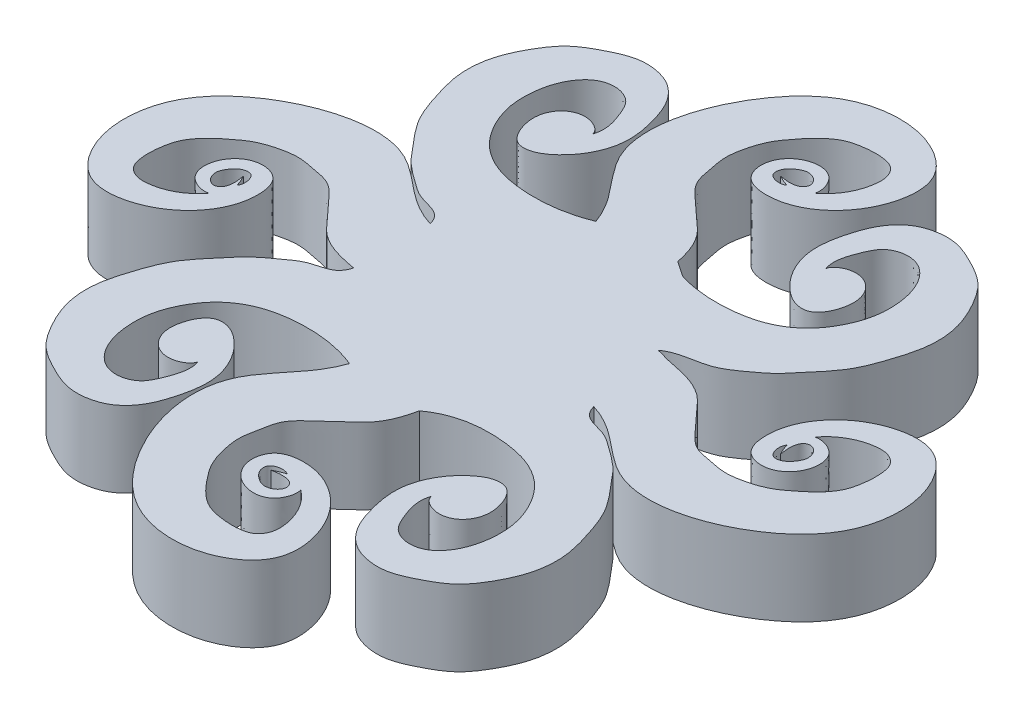
from build123d import *

# Parameters (mm, degrees)
BOSS_EXTRUDE2_DEPTH = 10
SKETCH2_R           = 13.166490973
BOSS_EXTRUDE4_DEPTH = 10


with BuildPart() as part:
    # Sketch1 → Boss-Extrude2 (new body)
    with BuildSketch(Plane(origin=(0, 0, 0), x_dir=(1, 0, 0), z_dir=(0, 1, 0))):
        with BuildLine():
            add(Edge.make_bspline(
                [(34.188363514, 44.956596514), (33.701598666, 43.048036253), (30.95739019, 43.115245722), (28.118998449, 40.970403917), (25.878188681, 39.331460779), (24.404677264, 37.426125449), (22.941084472, 35.794270593), (21.235407173, 33.479842018), (19.985078829, 30.008395243), (18.889058016, 26.247854831), (19.108830289, 22.745657785), (19.725757566, 20.92378151), (20.092106533, 20.092106533)],
                knots=[0, 0, 0, 0, 0.047266575, 0.084492057, 0.118112524, 0.141184856, 0.165634032, 0.192608699, 0.237940364, 0.289819658, 0.32418302, 0.354847276, 0.354847276, 0.354847276, 0.354847276], degree=3))
            Line((20.092106533, 20.092106533), (26.01328336, 26.01328336))
            add(Edge.make_bspline(
                [(26.01328336, 26.01328336), (26.052529787, 26.268426348), (26.278747771, 27.439968658), (27.14866517, 29.654095335), (29.108744684, 32.428855421), (31.966179785, 34.173665176), (33.996161891, 34.692283129), (34.836749566, 34.836749566)],
                knots=[0.460515809, 0.460515809, 0.460515809, 0.460515809, 0.478276136, 0.542635526, 0.623024021, 0.708168641, 0.766773984, 0.766773984, 0.766773984, 0.766773984], degree=3))
            Line((34.836749566, 34.836749566), (42.014455927, 42.014455927))
            add(Edge.make_bspline(
                [(34.188363514, 44.956596514), (34.412632763, 44.909046824), (35.135898032, 44.740206472), (36.778212553, 44.111022962), (39.947733796, 44.722787853), (41.031599473, 42.901571115), (42.014455927, 42.014455927)],
                knots=[0.810573593, 0.810573593, 0.810573593, 0.810573593, 0.822647339, 0.849801987, 0.902946428, 0.968114768, 0.968114768, 0.968114768, 0.968114768], degree=3))
        make_face()
        with BuildLine():
            Line((26.01328336, 26.01328336), (20.092106533, 20.092106533))
            add(Edge.make_bspline(
                [(20.092106533, 20.092106533), (20.391405304, 19.412646998), (21.173087456, 17.934573709), (22.855976348, 15.446940047), (25.899000157, 13.736428609), (29.019853456, 12.320498914), (31.692855633, 12.529433804), (34.075188007, 13.361697368), (36.025463952, 15.374095844), (37.304367596, 18.905964925), (38.234125799, 23.697087846), (36.050935714, 27.683689746), (33.885547102, 29.409321454), (32.695248955, 30.106562845), (30.959854801, 30.362175237), (29.737427553, 29.109049648), (29.167704554, 27.794524876), (28.848219551, 26.33981112), (29.051776005, 24.637379388), (29.977289897, 23.259457338), (31.684162076, 22.403328871), (33.422522957, 22.601417527), (34.534014203, 23.529934128), (34.637188493, 23.988642652), (34.646815974, 24.066379751)],
                knots=[0.354847276, 0.354847276, 0.354847276, 0.354847276, 0.379899275, 0.41085446, 0.455212464, 0.495953054, 0.524736546, 0.543496723, 0.580828475, 0.614309776, 0.670605327, 0.741152887, 0.752796809, 0.764260994, 0.788347673, 0.804360394, 0.819458631, 0.836969807, 0.854153952, 0.876412827, 0.889806592, 0.917326832, 0.931104592, 0.933826593, 0.933826593, 0.933826593, 0.933826593], degree=3))
            add(Edge.make_bspline(
                [(34.646815974, 24.066379751), (35.14201703, 22.640852122), (34.457931313, 20.557953149), (33.229845661, 17.848412965), (31.041923292, 16.974982467), (28.723356671, 17.471160138), (26.799485597, 19.52788522), (25.866296411, 22.561566295), (25.844067539, 24.913202835), (26.01328336, 26.01328336)],
                knots=[0, 0, 0, 0, 0.099619212, 0.145832416, 0.199041029, 0.246529323, 0.301572291, 0.383939961, 0.460515809, 0.460515809, 0.460515809, 0.460515809], degree=3))
        make_face()
        with BuildLine():
            add(Edge.make_bspline(
                [(79.907893467, 20.092106533), (79.608594696, 19.412646998), (78.826912544, 17.934573709), (77.144023652, 15.446940047), (74.100999843, 13.736428609), (70.980146544, 12.320498914), (68.307144367, 12.529433804), (65.924811993, 13.361697368), (63.974536048, 15.374095844), (62.695632404, 18.905964925), (61.765874201, 23.697087846), (63.949064286, 27.683689746), (66.114452898, 29.409321454), (67.304751045, 30.106562845), (69.040145199, 30.362175237), (70.262572447, 29.109049648), (70.832295446, 27.794524876), (71.151780449, 26.33981112), (70.948223995, 24.637379388), (70.022710103, 23.259457338), (68.315837924, 22.403328871), (66.577477043, 22.601417527), (65.465985797, 23.529934128), (65.362811507, 23.988642652), (65.353184026, 24.066379751)],
                knots=[0.354847276, 0.354847276, 0.354847276, 0.354847276, 0.379899275, 0.41085446, 0.455212464, 0.495953054, 0.524736546, 0.543496723, 0.580828475, 0.614309776, 0.670605327, 0.741152887, 0.752796809, 0.764260994, 0.788347673, 0.804360394, 0.819458631, 0.836969807, 0.854153952, 0.876412827, 0.889806592, 0.917326832, 0.931104592, 0.933826593, 0.933826593, 0.933826593, 0.933826593], degree=3))
            Line((79.907893467, 20.092106533), (73.986720472, 26.013279528))
            add(Edge.make_bspline(
                [(65.353184026, 24.066379751), (64.857982968, 22.640852128), (65.542068695, 20.557953125), (66.770154327, 17.848413003), (68.958076762, 16.974982309), (71.276643142, 17.471160691), (73.200515405, 19.527882257), (74.133699339, 22.561587505), (74.155943652, 24.91317945), (73.986720472, 26.013279528)],
                knots=[0, 0, 0, 0, 0.098273737, 0.143862778, 0.196352745, 0.243199654, 0.297499202, 0.3787544, 0.454296315, 0.454296315, 0.454296315, 0.454296315], degree=3))
        make_face()
        with BuildLine():
            Line((73.986720472, 26.013279528), (79.907893467, 20.092106533))
            add(Edge.make_bspline(
                [(65.811636486, 44.956596514), (66.298401334, 43.048036253), (69.04260981, 43.115245722), (71.881001551, 40.970403917), (74.121811319, 39.331460779), (75.595322736, 37.426125449), (77.058915528, 35.794270593), (78.764592827, 33.479842018), (80.014921171, 30.008395243), (81.110941984, 26.247854831), (80.891169711, 22.745657785), (80.274242434, 20.92378151), (79.907893467, 20.092106533)],
                knots=[0, 0, 0, 0, 0.047266575, 0.084492057, 0.118112524, 0.141184856, 0.165634032, 0.192608699, 0.237940364, 0.289819658, 0.32418302, 0.354847276, 0.354847276, 0.354847276, 0.354847276], degree=3))
            add(Edge.make_bspline(
                [(58.999511619, 43.561039694), (61.189200326, 45.409124558), (63.564168332, 45.615347007), (65.811636486, 44.956596514)],
                knots=[0.018252545, 0.018252545, 0.018252545, 0.018252545, 0.091662786, 0.091662786, 0.091662786, 0.091662786], degree=3))
            add(Edge.make_bspline(
                [(57.985544073, 42.014455927), (58.366591704, 42.436627849), (58.726230487, 42.929989082), (58.999511619, 43.561039694)],
                knots=[0.968114768, 0.968114768, 0.968114768, 0.968114768, 0.996106896, 0.996106896, 0.996106896, 0.996106896], degree=3))
            Line((57.985544073, 42.014455927), (65.166884419, 34.833115581))
            add(Edge.make_bspline(
                [(73.986720472, 26.013279528), (73.947473207, 26.268421402), (73.721246456, 27.439985024), (72.851273596, 29.654276415), (70.891559836, 32.427954896), (68.033533359, 34.176288831), (66.007033807, 34.687361047), (65.166884419, 34.833115581)],
                knots=[0.454296315, 0.454296315, 0.454296315, 0.454296315, 0.471816454, 0.535306594, 0.614609348, 0.698603989, 0.756359253, 0.756359253, 0.756359253, 0.756359253], degree=3))
        make_face()
        with BuildLine():
            add(Edge.make_bspline(
                [(20.092106533, 79.907893467), (20.391405304, 80.587353002), (21.173087456, 82.065426291), (22.855976348, 84.553059953), (25.899000157, 86.263571391), (29.019853456, 87.679501086), (31.692855633, 87.470566196), (34.075188007, 86.638302632), (36.025463952, 84.625904156), (37.304367596, 81.094035075), (38.234125799, 76.302912154), (36.050935714, 72.316310254), (33.885547102, 70.590678546), (32.695248955, 69.893437155), (30.959854801, 69.637824763), (29.737427553, 70.890950352), (29.167704554, 72.205475124), (28.848219551, 73.66018888), (29.051776005, 75.362620612), (29.977289897, 76.740542662), (31.684162076, 77.596671129), (33.422522957, 77.398582473), (34.534014203, 76.470065872), (34.637188493, 76.011357348), (34.646815974, 75.933620249)],
                knots=[0.354847276, 0.354847276, 0.354847276, 0.354847276, 0.379899275, 0.41085446, 0.455212464, 0.495953054, 0.524736546, 0.543496723, 0.580828475, 0.614309776, 0.670605327, 0.741152887, 0.752796809, 0.764260994, 0.788347673, 0.804360394, 0.819458631, 0.836969807, 0.854153952, 0.876412827, 0.889806592, 0.917326832, 0.931104592, 0.933826593, 0.933826593, 0.933826593, 0.933826593], degree=3))
            Line((20.092106533, 79.907893467), (26.01328336, 73.98671664))
            add(Edge.make_bspline(
                [(34.646815974, 75.933620249), (35.14201703, 77.359147878), (34.457931313, 79.442046851), (33.229845661, 82.151587035), (31.041923292, 83.025017533), (28.723356671, 82.528839862), (26.799485597, 80.47211478), (25.866296411, 77.438433705), (25.844067539, 75.086797165), (26.01328336, 73.98671664)],
                knots=[0, 0, 0, 0, 0.099619212, 0.145832416, 0.199041029, 0.246529323, 0.301572291, 0.383939961, 0.460515809, 0.460515809, 0.460515809, 0.460515809], degree=3))
        make_face()
        with BuildLine():
            Line((26.01328336, 73.98671664), (20.092106533, 79.907893467))
            add(Edge.make_bspline(
                [(34.188363514, 55.043403486), (33.701598666, 56.951963747), (30.95739019, 56.884754278), (28.118998449, 59.029596083), (25.878188681, 60.668539221), (24.404677264, 62.573874551), (22.941084472, 64.205729407), (21.235407173, 66.520157982), (19.985078829, 69.991604757), (18.889058016, 73.752145169), (19.108830289, 77.254342215), (19.725757566, 79.07621849), (20.092106533, 79.907893467)],
                knots=[0, 0, 0, 0, 0.047266575, 0.084492057, 0.118112524, 0.141184856, 0.165634032, 0.192608699, 0.237940364, 0.289819658, 0.32418302, 0.354847276, 0.354847276, 0.354847276, 0.354847276], degree=3))
            add(Edge.make_bspline(
                [(41.228865774, 56.63831337), (38.976587284, 54.606309361), (36.514201974, 54.361682043), (34.188363514, 55.043403486)],
                knots=[0.015692694, 0.015692694, 0.015692694, 0.015692694, 0.091662786, 0.091662786, 0.091662786, 0.091662786], degree=3))
            ThreePointArc((41.228865774, 56.63831337), (41.538778856, 57.029063717), (41.866085127, 57.405364869))
            ThreePointArc((41.866085127, 57.405364869), (42.041771895, 57.593853135), (42.221825407, 57.778174593))
            Line((42.221825407, 57.778174593), (34.836749566, 65.163250434))
            add(Edge.make_bspline(
                [(26.01328336, 73.98671664), (26.052529787, 73.731573652), (26.278747771, 72.560031342), (27.14866517, 70.345904665), (29.108744684, 67.571144579), (31.966179785, 65.826334824), (33.996161891, 65.307716871), (34.836749566, 65.163250434)],
                knots=[0.460515809, 0.460515809, 0.460515809, 0.460515809, 0.478276136, 0.542635526, 0.623024021, 0.708168641, 0.766773984, 0.766773984, 0.766773984, 0.766773984], degree=3))
        make_face()
        with BuildLine():
            add(Edge.make_bspline(
                [(16.160494625, 43.96111936), (14.986864586, 42.379235873), (12.592744084, 41.012743048), (9.465709528, 40.96551986), (8.026422717, 41.910411497), (7.550806508, 43.748330363), (7.647195031, 45.75277335), (8.069282603, 47.971716016), (9.432801166, 49.882198225), (11.219922046, 51.401479152), (13.316786407, 52.95305245), (15.672674157, 53.673961961), (18.087107893, 54.068440293), (20.330842421, 53.550169721), (22.892165795, 53.186443439), (24.769702556, 51.12420354), (26.684889568, 49.06748532), (28.919014682, 46.346067881), (31.874813568, 45.376238518), (33.79367813, 45.040277927), (34.188363514, 44.956596514)],
                knots=[0, 0, 0, 0, 0.103133744, 0.133672356, 0.160054586, 0.186139677, 0.228666647, 0.265873413, 0.302525941, 0.34902888, 0.389122541, 0.4381572, 0.476950983, 0.515572502, 0.558652472, 0.608310362, 0.655131306, 0.708599715, 0.789325333, 0.810573593, 0.810573593, 0.810573593, 0.810573593], degree=3))
            add(Edge.make_bspline(
                [(34.188363514, 44.956596514), (34.412632763, 44.909046824), (35.135898032, 44.740206472), (36.778212553, 44.111022962), (39.947733796, 44.722787853), (41.031599473, 42.901571115), (42.014455927, 42.014455927)],
                knots=[0.810573593, 0.810573593, 0.810573593, 0.810573593, 0.822647339, 0.849801987, 0.902946428, 0.968114768, 0.968114768, 0.968114768, 0.968114768], degree=3))
            Line((42.014455927, 42.014455927), (42.221825407, 42.221825407))
            ThreePointArc((42.221825407, 42.221825407), (42.041771895, 42.406146865), (41.866085127, 42.594635131))
            ThreePointArc((41.866085127, 42.594635131), (39.011305998, 49.501397827), (41.228865774, 56.63831337))
            add(Edge.make_bspline(
                [(41.228865774, 56.63831337), (38.976587284, 54.606309361), (36.514201974, 54.361682043), (34.188363514, 55.043403486)],
                knots=[0.015692694, 0.015692694, 0.015692694, 0.015692694, 0.091662786, 0.091662786, 0.091662786, 0.091662786], degree=3))
            add(Edge.make_bspline(
                [(34.188363514, 55.043403486), (32.988757012, 55.395017534), (29.597040142, 57.138700626), (22.985132601, 64.13491873), (10.103143612, 60.465996346), (1.846885834, 51.957990237), (1.634403442, 42.951143194), (6.767093741, 36.729262075), (13.487499365, 37.728070412), (18.147246483, 41.515948147), (19.922544307, 46.038195425), (19.184657897, 50.305501367), (15.417936423, 51.104416641), (12.630967645, 48.726147208), (12.560989705, 44.684698735), (15.201485328, 43.712661691), (16.160494625, 43.96111936)],
                knots=[0.091662786, 0.091662786, 0.091662786, 0.091662786, 0.130846168, 0.205907606, 0.373668348, 0.458524244, 0.563429024, 0.616001906, 0.684326796, 0.743988773, 0.794856123, 0.830050979, 0.857943881, 0.895209986, 0.928487465, 0.961873919, 0.961873919, 0.961873919, 0.961873919], degree=3))
        make_face()
        with BuildLine():
            add(Edge.make_bspline(
                [(16.480040826, 48.178626232), (16.592128106, 47.528012831), (16.737195952, 46.59846685), (16.301672382, 45.417068995), (15.580197675, 45.116345164), (14.941408745, 45.337928813), (14.493316803, 45.783133929), (14.277188548, 46.356103882), (14.1963921, 46.948802008), (14.438639408, 47.616279928), (14.910750096, 48.31149619), (15.627269466, 48.946980069), (17.316467934, 49.150329476), (17.504986229, 47.195958075), (17.092499363, 46.720147552)],
                knots=[0, 0, 0, 0, 0.16636553, 0.241726144, 0.29922749, 0.344909014, 0.407108122, 0.454045417, 0.499648781, 0.556760972, 0.630203201, 0.713356713, 0.798617516, 1, 1, 1, 1], degree=3))
            add(Edge.make_bspline(
                [(17.092499363, 46.720147552), (16.962306122, 47.149811619), (16.76240491, 47.634622725), (16.480040826, 48.178626232)],
                knots=[0.992293125, 0.992293125, 0.992293125, 0.992293125, 1, 1, 1, 1], degree=3))
        make_face(mode=Mode.SUBTRACT)
        with BuildLine():
            add(Edge.make_bspline(
                [(63.619252851, 55.615166428), (65.217749299, 56.807977108), (68.566089002, 56.61671767), (71.887711223, 59.017839913), (74.120685104, 60.670512487), (75.595591616, 62.57340344), (77.058834536, 64.205871316), (78.764632843, 66.520087869), (80.014906002, 69.991631335), (81.110944653, 73.752140493), (80.891169349, 77.25434267), (80.27424218, 79.076218783), (79.907893422, 79.907893422)],
                knots=[0, 0, 0, 0, 0.064389944, 0.100946377, 0.133962587, 0.156620243, 0.180629997, 0.207119851, 0.251636775, 0.302583648, 0.336329402, 0.366442526, 0.366442526, 0.366442526, 0.366442526], degree=3))
            Line((79.907893422, 79.907893422), (73.986716963, 73.986716963))
            add(Edge.make_bspline(
                [(73.986716963, 73.986716963), (73.947470464, 73.731574111), (73.721251671, 72.56002965), (72.85132918, 70.34588619), (70.891283414, 67.571236458), (68.033804779, 65.826069284), (66.004157648, 65.308221706), (65.163622957, 65.163622957)],
                knots=[0.479848557, 0.479848557, 0.479848557, 0.479848557, 0.498354438, 0.565415671, 0.649178921, 0.737897959, 0.798956978, 0.798956978, 0.798956978, 0.798956978], degree=3))
            Line((65.163622957, 65.163622957), (57.985544073, 57.985544073))
            add(Edge.make_bspline(
                [(63.619252851, 55.615166428), (62.609079309, 55.770749147), (60.04783606, 55.284656108), (58.968400527, 57.098428885), (57.985544073, 57.985544073)],
                knots=[0.850285574, 0.850285574, 0.850285574, 0.850285574, 0.902946428, 0.968114768, 0.968114768, 0.968114768, 0.968114768], degree=3))
        make_face()
        with BuildLine():
            Line((73.986716963, 73.986716963), (79.907893422, 79.907893422))
            add(Edge.make_bspline(
                [(79.907893422, 79.907893422), (79.608594677, 80.587353011), (78.826912774, 82.065425919), (77.144023601, 84.553060043), (74.100999858, 86.263571365), (70.980146542, 87.67950109), (68.307144368, 87.470566196), (65.924811993, 86.638302632), (63.974536048, 84.625904156), (62.695632404, 81.094035075), (61.765874201, 76.302912154), (63.949064286, 72.316310254), (66.114452898, 70.590678546), (67.304751045, 69.893437155), (69.040145199, 69.637824763), (70.262572447, 70.890950352), (70.832295446, 72.205475124), (71.151780449, 73.66018888), (70.948223995, 75.362620612), (70.022710103, 76.740542662), (68.315837924, 77.596671129), (66.577477043, 77.398582473), (65.465985797, 76.470065872), (65.362811507, 76.011357348), (65.353184026, 75.933620249)],
                knots=[0.366442526, 0.366442526, 0.366442526, 0.366442526, 0.391044274, 0.421443106, 0.465003868, 0.505012233, 0.533278402, 0.551701404, 0.588362197, 0.621241742, 0.6765255, 0.745805117, 0.757239764, 0.768497904, 0.792151676, 0.807876602, 0.822703481, 0.83989993, 0.856775226, 0.878634045, 0.891787086, 0.918812708, 0.932342842, 0.93501592, 0.93501592, 0.93501592, 0.93501592], degree=3))
            add(Edge.make_bspline(
                [(65.353184026, 75.933620249), (64.857982969, 77.359147877), (65.542068688, 79.442046853), (66.770154338, 82.151587031), (68.958076713, 83.025017549), (71.276643312, 82.528839806), (73.200514495, 80.472115082), (74.133703218, 77.438431519), (74.155933495, 75.086799504), (73.986716963, 73.986716963)],
                knots=[0, 0, 0, 0, 0.103801283, 0.151954543, 0.207396883, 0.256878763, 0.314232465, 0.400057977, 0.479848557, 0.479848557, 0.479848557, 0.479848557], degree=3))
        make_face()
        with BuildLine():
            add(Edge.make_bspline(
                [(58.999511619, 43.561039694), (61.189200326, 45.409124558), (63.564168332, 45.615347007), (65.811636486, 44.956596514)],
                knots=[0.018252545, 0.018252545, 0.018252545, 0.018252545, 0.091662786, 0.091662786, 0.091662786, 0.091662786], degree=3))
            add(Edge.make_bspline(
                [(65.811636486, 44.956596514), (67.011242988, 44.604982466), (70.402959858, 42.861299374), (77.014867399, 35.86508127), (89.896856388, 39.534003654), (98.153114166, 48.042009763), (98.365596558, 57.048856806), (93.232906259, 63.270737925), (86.512500635, 62.271929588), (81.852753517, 58.484051853), (80.077455693, 53.961804575), (80.815342103, 49.694498633), (84.582063577, 48.895583359), (87.369032355, 51.273852792), (87.439010295, 55.315301265), (84.798514672, 56.287338309), (83.839505375, 56.03888064)],
                knots=[0.091662786, 0.091662786, 0.091662786, 0.091662786, 0.130846168, 0.205907606, 0.373668348, 0.458524244, 0.563429024, 0.616001906, 0.684326796, 0.743988773, 0.794856123, 0.830050979, 0.857943881, 0.895209986, 0.928487465, 0.961873919, 0.961873919, 0.961873919, 0.961873919], degree=3))
            add(Edge.make_bspline(
                [(83.839505375, 56.03888064), (85.013135414, 57.620764127), (87.407255916, 58.987256952), (90.534290472, 59.03448014), (91.973577283, 58.089588503), (92.449193492, 56.251669637), (92.352804969, 54.24722665), (91.930717397, 52.028283984), (90.567198834, 50.117801775), (88.780077954, 48.598520848), (86.683213593, 47.04694755), (84.327325843, 46.326038039), (81.912892107, 45.931559707), (79.669157579, 46.449830279), (77.107834205, 46.813556561), (75.230297444, 48.87579646), (73.315110432, 50.93251468), (71.080985318, 53.653932119), (67.895599183, 54.699091525), (65.241878897, 55.115064238), (64.166652748, 55.526991767), (63.647047863, 55.610785299)],
                knots=[0, 0, 0, 0, 0.103133744, 0.133672356, 0.160054586, 0.186139677, 0.228666647, 0.265873413, 0.302525941, 0.34902888, 0.389122541, 0.4381572, 0.476950983, 0.515572502, 0.558652472, 0.608310362, 0.655131306, 0.708599715, 0.789325333, 0.822647339, 0.849801987, 0.849801987, 0.849801987, 0.849801987], degree=3))
            add(Edge.make_bspline(
                [(63.647047863, 55.610785299), (63.637794424, 55.612277545), (63.628529309, 55.613737706), (63.619252851, 55.615166428)],
                knots=[0.849801987, 0.849801987, 0.849801987, 0.849801987, 0.850285574, 0.850285574, 0.850285574, 0.850285574], degree=3))
            add(Edge.make_bspline(
                [(63.619252851, 55.615166428), (62.609079309, 55.770749147), (60.04783606, 55.284656108), (58.968400527, 57.098428885), (57.985544073, 57.985544073)],
                knots=[0.850285574, 0.850285574, 0.850285574, 0.850285574, 0.902946428, 0.968114768, 0.968114768, 0.968114768, 0.968114768], degree=3))
            add(Edge.make_bspline(
                [(57.985544073, 57.985544073), (58.419587249, 57.5046571), (58.825852446, 56.931402004), (59.108348304, 56.167494723)],
                knots=[0.968114768, 0.968114768, 0.968114768, 0.968114768, 1, 1, 1, 1], degree=3))
            ThreePointArc((59.108348304, 56.167494723), (60.516459275, 53.225536285), (61, 50))
            ThreePointArc((61, 50), (60.516459275, 46.774463715), (59.108348304, 43.832505277))
            add(Edge.make_bspline(
                [(58.999511619, 43.561039694), (59.037519157, 43.648805286), (59.073856294, 43.739234181), (59.108348304, 43.832505277)],
                knots=[0.996106896, 0.996106896, 0.996106896, 0.996106896, 1, 1, 1, 1], degree=3))
        make_face()
        with BuildLine():
            add(Edge.make_bspline(
                [(83.519959174, 51.821373768), (83.407871894, 52.471987169), (83.262804048, 53.40153315), (83.698327618, 54.582931005), (84.419802325, 54.883654836), (85.058591255, 54.662071187), (85.506683197, 54.216866071), (85.722811452, 53.643896118), (85.8036079, 53.051197992), (85.561360592, 52.383720072), (85.089249904, 51.68850381), (84.372730534, 51.053019931), (82.683532066, 50.849670524), (82.495013771, 52.804041925), (82.907500637, 53.279852448)],
                knots=[0, 0, 0, 0, 0.16636553, 0.241726144, 0.29922749, 0.344909014, 0.407108122, 0.454045417, 0.499648781, 0.556760972, 0.630203201, 0.713356713, 0.798617516, 1, 1, 1, 1], degree=3))
            add(Edge.make_bspline(
                [(82.907500637, 53.279852448), (83.037693878, 52.850188381), (83.23759509, 52.365377275), (83.519959174, 51.821373768)],
                knots=[0.992293125, 0.992293125, 0.992293125, 0.992293125, 1, 1, 1, 1], degree=3))
        make_face(mode=Mode.SUBTRACT)
        with BuildLine():
            Line((42.014455927, 42.014455927), (34.836749566, 34.836749566))
            add(Edge.make_bspline(
                [(34.836749566, 34.836749566), (35.127532864, 34.886724635), (38.490614827, 35.369450815), (41.950755989, 34.971413705), (44.827882558, 33.782431504)],
                knots=[0.766773984, 0.766773984, 0.766773984, 0.766773984, 0.787047246, 1, 1, 1, 1], degree=3))
            add(Edge.make_bspline(
                [(43.561039694, 41.000488381), (45.520791717, 38.678491725), (45.634273864, 36.148148995), (44.827882558, 33.782431504)],
                knots=[0.018252545, 0.018252545, 0.018252545, 0.018252545, 0.096098466, 0.096098466, 0.096098466, 0.096098466], degree=3))
            add(Edge.make_bspline(
                [(42.014455927, 42.014455927), (42.436627849, 41.633408296), (42.929989082, 41.273769513), (43.561039694, 41.000488381)],
                knots=[0.968114768, 0.968114768, 0.968114768, 0.968114768, 0.996106896, 0.996106896, 0.996106896, 0.996106896], degree=3))
        make_face()
        with BuildLine():
            add(Edge.make_bspline(
                [(65.166884419, 34.833115581), (64.875106499, 34.883735096), (61.309745267, 35.407065501), (57.596457215, 35.058299276), (54.806676969, 32.993134393)],
                knots=[0.756359253, 0.756359253, 0.756359253, 0.756359253, 0.776417246, 1, 1, 1, 1], degree=3))
            Line((65.166884419, 34.833115581), (57.985544073, 42.014455927))
            add(Edge.make_bspline(
                [(54.806676969, 32.993134393), (54.936903945, 33.621537936), (55.115064238, 34.758121103), (55.888977038, 36.778212553), (55.277212147, 39.947733796), (57.098428885, 41.031599473), (57.985544073, 42.014455927)],
                knots=[0.789325333, 0.789325333, 0.789325333, 0.789325333, 0.822647339, 0.849801987, 0.902946428, 0.968114768, 0.968114768, 0.968114768, 0.968114768], degree=3))
        make_face()
        with BuildLine():
            add(Edge.make_bspline(
                [(34.836749566, 65.163250434), (35.127532864, 65.113275365), (38.490614827, 64.630549185), (41.950755989, 65.028586295), (44.827882558, 66.217568496)],
                knots=[0.766773984, 0.766773984, 0.766773984, 0.766773984, 0.787047246, 1, 1, 1, 1], degree=3))
            Line((34.836749566, 65.163250434), (42.221825407, 57.778174593))
            ThreePointArc((42.221825407, 57.778174593), (42.406146865, 57.958228105), (42.594635131, 58.133914873))
            ThreePointArc((42.594635131, 58.133914873), (42.970936283, 58.461221144), (43.36168663, 58.771134226))
            add(Edge.make_bspline(
                [(43.36168663, 58.771134226), (45.512333639, 61.154916923), (45.660790878, 63.7740578), (44.827882558, 66.217568496)],
                knots=[0.015692694, 0.015692694, 0.015692694, 0.015692694, 0.096098466, 0.096098466, 0.096098466, 0.096098466], degree=3))
        make_face()
        with BuildLine():
            add(Edge.make_bspline(
                [(42.271128523, 57.728871477), (41.929759507, 57.31922896), (41.581893616, 56.956814831), (41.228865774, 56.63831337)],
                knots=[0.003784949, 0.003784949, 0.003784949, 0.003784949, 0.015692694, 0.015692694, 0.015692694, 0.015692694], degree=3))
            ThreePointArc((41.228865774, 56.63831337), (39.011305998, 49.501397827), (41.866085127, 42.594635131))
            add(Edge.make_bspline(
                [(41.866085127, 42.594635131), (42.005942181, 42.48748457), (42.140921153, 42.379634744), (42.271128523, 42.271128523)],
                knots=[0, 0, 0, 0, 0.003784949, 0.003784949, 0.003784949, 0.003784949], degree=3))
            Line((42.271128523, 42.271128523), (50, 50))
            Line((50, 50), (42.271128523, 57.728871477))
        make_face()
        with BuildLine():
            add(Edge.make_bspline(
                [(43.561039694, 41.000488381), (45.520791717, 38.678491725), (45.634273864, 36.148148995), (44.827882558, 33.782431504)],
                knots=[0.018252545, 0.018252545, 0.018252545, 0.018252545, 0.096098466, 0.096098466, 0.096098466, 0.096098466], degree=3))
            add(Edge.make_bspline(
                [(44.827882558, 33.782431504), (44.467937629, 32.726457801), (42.751255499, 29.493041108), (35.86508127, 22.985132601), (39.534003654, 10.103143612), (48.042009763, 1.846885834), (57.048856806, 1.634403442), (63.270737925, 6.767093741), (62.271929588, 13.487499365), (58.484051853, 18.147246483), (53.961804575, 19.922544307), (49.694498633, 19.184657897), (48.895583359, 15.417936423), (51.273852792, 12.630967645), (55.315301265, 12.560989705), (56.287338309, 15.201485328), (56.03888064, 16.160494625)],
                knots=[0.096098466, 0.096098466, 0.096098466, 0.096098466, 0.130846168, 0.205907606, 0.373668348, 0.458524244, 0.563429024, 0.616001906, 0.684326796, 0.743988773, 0.794856123, 0.830050979, 0.857943881, 0.895209986, 0.928487465, 0.961873919, 0.961873919, 0.961873919, 0.961873919], degree=3))
            add(Edge.make_bspline(
                [(56.03888064, 16.160494625), (57.620764127, 14.986864586), (58.987256952, 12.592744084), (59.03448014, 9.465709528), (58.089588503, 8.026422717), (56.251669637, 7.550806508), (54.24722665, 7.647195031), (52.028283984, 8.069282603), (50.117801775, 9.432801166), (48.598520848, 11.219922046), (47.04694755, 13.316786407), (46.326038039, 15.672674157), (45.931559707, 18.087107893), (46.449830279, 20.330842421), (46.813556561, 22.892165795), (48.87579646, 24.769702556), (50.93251468, 26.684889568), (53.653932119, 28.919014682), (54.491190178, 31.470769179), (54.806676969, 32.993134393)],
                knots=[0, 0, 0, 0, 0.103133744, 0.133672356, 0.160054586, 0.186139677, 0.228666647, 0.265873413, 0.302525941, 0.34902888, 0.389122541, 0.4381572, 0.476950983, 0.515572502, 0.558652472, 0.608310362, 0.655131306, 0.708599715, 0.789325333, 0.789325333, 0.789325333, 0.789325333], degree=3))
            add(Edge.make_bspline(
                [(54.806676969, 32.993134393), (54.936903945, 33.621537936), (55.115064238, 34.758121103), (55.888977038, 36.778212553), (55.277212147, 39.947733796), (57.098428885, 41.031599473), (57.985544073, 42.014455927)],
                knots=[0.789325333, 0.789325333, 0.789325333, 0.789325333, 0.822647339, 0.849801987, 0.902946428, 0.968114768, 0.968114768, 0.968114768, 0.968114768], degree=3))
            Line((57.985544073, 42.014455927), (57.778174593, 42.221825407))
            ThreePointArc((57.778174593, 42.221825407), (57.593853135, 42.041771895), (57.405364869, 41.866085127))
            ThreePointArc((57.405364869, 41.866085127), (50.787693311, 39.028239009), (43.832505277, 40.891651696))
            add(Edge.make_bspline(
                [(43.561039694, 41.000488381), (43.648805286, 40.962480843), (43.739234181, 40.926143706), (43.832505277, 40.891651696)],
                knots=[0.996106896, 0.996106896, 0.996106896, 0.996106896, 1, 1, 1, 1], degree=3))
        make_face()
        with BuildLine():
            add(Edge.make_bspline(
                [(51.821373768, 16.480040826), (52.471987169, 16.592128106), (53.40153315, 16.737195952), (54.582931005, 16.301672382), (54.883654836, 15.580197675), (54.662071187, 14.941408745), (54.216866071, 14.493316803), (53.643896118, 14.277188548), (53.051197992, 14.1963921), (52.383720072, 14.438639408), (51.68850381, 14.910750096), (51.053019931, 15.627269466), (50.849670524, 17.316467934), (52.804041925, 17.504986229), (53.279852448, 17.092499363)],
                knots=[0, 0, 0, 0, 0.16636553, 0.241726144, 0.29922749, 0.344909014, 0.407108122, 0.454045417, 0.499648781, 0.556760972, 0.630203201, 0.713356713, 0.798617516, 1, 1, 1, 1], degree=3))
            add(Edge.make_bspline(
                [(53.279852448, 17.092499363), (52.850188381, 16.962306122), (52.365377275, 16.76240491), (51.821373768, 16.480040826)],
                knots=[0.992293125, 0.992293125, 0.992293125, 0.992293125, 1, 1, 1, 1], degree=3))
        make_face(mode=Mode.SUBTRACT)
        with BuildLine():
            Line((57.985544073, 57.985544073), (65.163622957, 65.163622957))
            add(Edge.make_bspline(
                [(65.163622957, 65.163622957), (64.872735525, 65.11358105), (62.090237287, 64.713260631), (59.239111577, 64.908530138), (56.838699435, 65.649514164)],
                knots=[0.798956978, 0.798956978, 0.798956978, 0.798956978, 0.820087933, 1, 1, 1, 1], degree=3))
            add(Edge.make_bspline(
                [(56.838699435, 65.649514164), (54.806676969, 67.006865607)],
                knots=[0, 0, 1, 1], degree=1))
            add(Edge.make_bspline(
                [(54.806676969, 67.006865607), (54.936903945, 66.378462064), (55.115064238, 65.241878897), (55.888977038, 63.221787447), (55.277212147, 60.052266204), (57.098428885, 58.968400527), (57.985544073, 57.985544073)],
                knots=[0.789325333, 0.789325333, 0.789325333, 0.789325333, 0.822647339, 0.849801987, 0.902946428, 0.968114768, 0.968114768, 0.968114768, 0.968114768], degree=3))
        make_face()
        with BuildLine():
            add(Edge.make_bspline(
                [(57.985544073, 57.985544073), (57.5046571, 58.419587249), (56.931402004, 58.825852446), (56.167494723, 59.108348304)],
                knots=[0.968114768, 0.968114768, 0.968114768, 0.968114768, 1, 1, 1, 1], degree=3))
            add(Edge.make_bspline(
                [(54.806676969, 67.006865607), (54.936903945, 66.378462064), (55.115064238, 65.241878897), (55.888977038, 63.221787447), (55.277212147, 60.052266204), (57.098428885, 58.968400527), (57.985544073, 57.985544073)],
                knots=[0.789325333, 0.789325333, 0.789325333, 0.789325333, 0.822647339, 0.849801987, 0.902946428, 0.968114768, 0.968114768, 0.968114768, 0.968114768], degree=3))
            add(Edge.make_bspline(
                [(56.03888064, 83.839505375), (57.620764127, 85.013135414), (58.987256952, 87.407255916), (59.03448014, 90.534290472), (58.089588503, 91.973577283), (56.251669637, 92.449193492), (54.24722665, 92.352804969), (52.028283984, 91.930717397), (50.117801775, 90.567198834), (48.598520848, 88.780077954), (47.04694755, 86.683213593), (46.326038039, 84.327325843), (45.931559707, 81.912892107), (46.449830279, 79.669157579), (46.813556561, 77.107834205), (48.87579646, 75.230297444), (50.93251468, 73.315110432), (53.653932119, 71.080985318), (54.491190178, 68.529230821), (54.806676969, 67.006865607)],
                knots=[0, 0, 0, 0, 0.103133744, 0.133672356, 0.160054586, 0.186139677, 0.228666647, 0.265873413, 0.302525941, 0.34902888, 0.389122541, 0.4381572, 0.476950983, 0.515572502, 0.558652472, 0.608310362, 0.655131306, 0.708599715, 0.789325333, 0.789325333, 0.789325333, 0.789325333], degree=3))
            add(Edge.make_bspline(
                [(44.827882558, 66.217568496), (44.467937629, 67.273542199), (42.751255499, 70.506958892), (35.86508127, 77.014867399), (39.534003654, 89.896856388), (48.042009763, 98.153114166), (57.048856806, 98.365596558), (63.270737925, 93.232906259), (62.271929588, 86.512500635), (58.484051853, 81.852753517), (53.961804575, 80.077455693), (49.694498633, 80.815342103), (48.895583359, 84.582063577), (51.273852792, 87.369032355), (55.315301265, 87.439010295), (56.287338309, 84.798514672), (56.03888064, 83.839505375)],
                knots=[0.096098466, 0.096098466, 0.096098466, 0.096098466, 0.130846168, 0.205907606, 0.373668348, 0.458524244, 0.563429024, 0.616001906, 0.684326796, 0.743988773, 0.794856123, 0.830050979, 0.857943881, 0.895209986, 0.928487465, 0.961873919, 0.961873919, 0.961873919, 0.961873919], degree=3))
            add(Edge.make_bspline(
                [(43.36168663, 58.771134226), (45.512333639, 61.154916923), (45.660790878, 63.7740578), (44.827882558, 66.217568496)],
                knots=[0.015692694, 0.015692694, 0.015692694, 0.015692694, 0.096098466, 0.096098466, 0.096098466, 0.096098466], degree=3))
            ThreePointArc((43.36168663, 58.771134226), (49.710438464, 60.996188163), (56.167494723, 59.108348304))
        make_face()
        with BuildLine():
            add(Edge.make_bspline(
                [(53.279852448, 82.907500637), (52.850188381, 83.037693878), (52.365377275, 83.23759509), (51.821373768, 83.519959174)],
                knots=[0.992293125, 0.992293125, 0.992293125, 0.992293125, 1, 1, 1, 1], degree=3))
            add(Edge.make_bspline(
                [(51.821373768, 83.519959174), (52.471987169, 83.407871894), (53.40153315, 83.262804048), (54.582931005, 83.698327618), (54.883654836, 84.419802325), (54.662071187, 85.058591255), (54.216866071, 85.506683197), (53.643896118, 85.722811452), (53.051197992, 85.8036079), (52.383720072, 85.561360592), (51.68850381, 85.089249904), (51.053019931, 84.372730534), (50.849670524, 82.683532066), (52.804041925, 82.495013771), (53.279852448, 82.907500637)],
                knots=[0, 0, 0, 0, 0.16636553, 0.241726144, 0.29922749, 0.344909014, 0.407108122, 0.454045417, 0.499648781, 0.556760972, 0.630203201, 0.713356713, 0.798617516, 1, 1, 1, 1], degree=3))
        make_face(mode=Mode.SUBTRACT)
        with BuildLine():
            ThreePointArc((58.771134226, 43.36168663), (58.942840233, 43.594876382), (59.108348304, 43.832505277))
            ThreePointArc((59.108348304, 43.832505277), (60.516459275, 46.774463715), (61, 50))
            ThreePointArc((61, 50), (60.516459275, 53.225536285), (59.108348304, 56.167494723))
            ThreePointArc((59.108348304, 56.167494723), (58.481582182, 57.004481687), (57.778174593, 57.778174593))
            Line((57.778174593, 57.778174593), (50, 50))
            Line((50, 50), (57.728871477, 42.271128523))
            add(Edge.make_bspline(
                [(57.728871477, 42.271128523), (58.070240493, 42.68077104), (58.418106384, 43.043185169), (58.771134226, 43.36168663)],
                knots=[0.003784949, 0.003784949, 0.003784949, 0.003784949, 0.015692694, 0.015692694, 0.015692694, 0.015692694], degree=3))
        make_face()
        with BuildLine():
            add(Edge.make_bspline(
                [(42.271128523, 57.728871477), (42.68077104, 58.070240493), (43.043185169, 58.418106384), (43.36168663, 58.771134226)],
                knots=[0.003784949, 0.003784949, 0.003784949, 0.003784949, 0.015692694, 0.015692694, 0.015692694, 0.015692694], degree=3))
            Line((42.271128523, 57.728871477), (50, 50))
            Line((50, 50), (57.778174593, 57.778174593))
            ThreePointArc((57.778174593, 57.778174593), (57.004481687, 58.481582182), (56.167494723, 59.108348304))
            ThreePointArc((56.167494723, 59.108348304), (49.710438464, 60.996188163), (43.36168663, 58.771134226))
        make_face()
        with BuildLine():
            Line((50, 50), (42.271128523, 42.271128523))
            add(Edge.make_bspline(
                [(42.271128523, 42.271128523), (42.68077104, 41.929759507), (43.043185169, 41.581893616), (43.36168663, 41.228865774)],
                knots=[0.003784949, 0.003784949, 0.003784949, 0.003784949, 0.015692694, 0.015692694, 0.015692694, 0.015692694], degree=3))
            ThreePointArc((43.36168663, 41.228865774), (43.594876382, 41.057159767), (43.832505277, 40.891651696))
            ThreePointArc((43.832505277, 40.891651696), (50.787693311, 39.028239009), (57.405364869, 41.866085127))
            add(Edge.make_bspline(
                [(57.405364869, 41.866085127), (57.51251543, 42.005942181), (57.620365256, 42.140921153), (57.728871477, 42.271128523)],
                knots=[0, 0, 0, 0, 0.003784949, 0.003784949, 0.003784949, 0.003784949], degree=3))
            Line((57.728871477, 42.271128523), (50, 50))
        make_face()
    extrude(amount=BOSS_EXTRUDE2_DEPTH)

    # Sketch2 → Boss-Extrude4 (add)
    with BuildSketch(Plane(origin=(0, 0, 0), x_dir=(1, 0, 0), z_dir=(0, 1, 0))):
        with Locations((51.336199781, 49.053362674)):
            Circle(SKETCH2_R)
    extrude(amount=BOSS_EXTRUDE4_DEPTH)


solid = part.part
